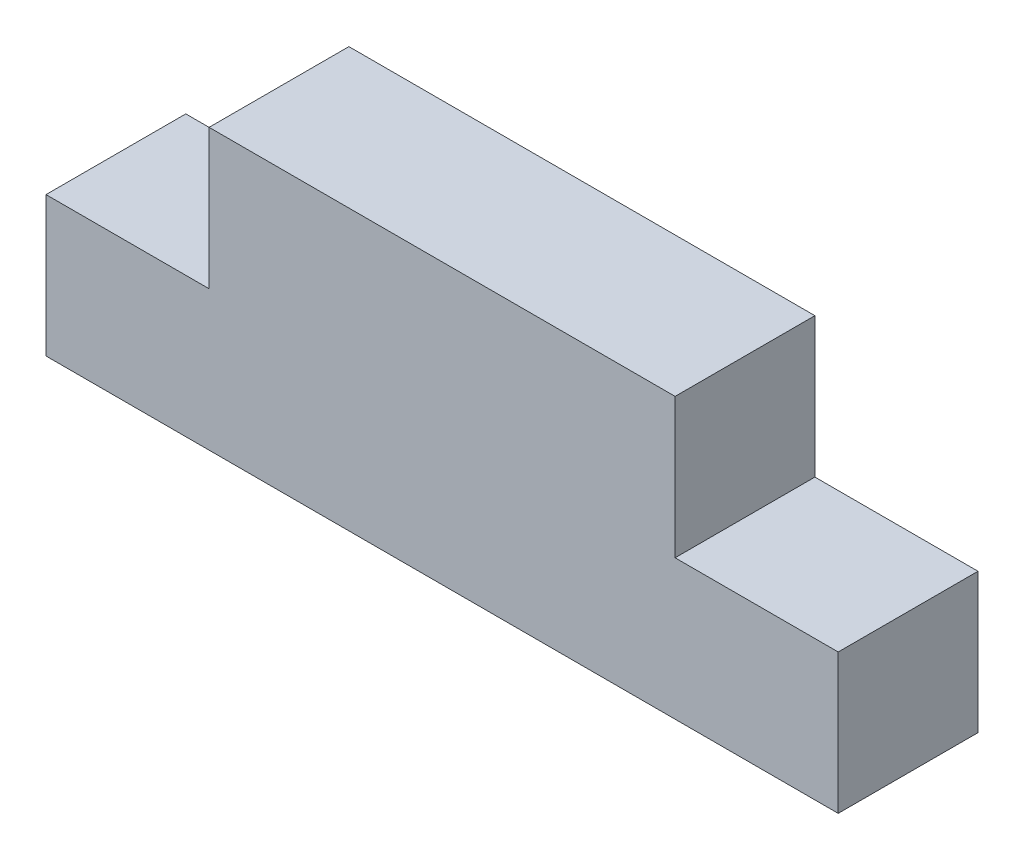
from build123d import *

# Parameters (mm, degrees)
RESSALTO_EXTRUS_O1_DEPTH = 6


with BuildPart() as part:
    # Esboço1 → Ressalto-extrusão1 (new body)
    with BuildSketch(Plane.XY):
        Polygon((7, 12), (7, 6), (0, 6), (0, 0), (34, 0), (34, 6), (27, 6), (27, 12), align=None)
    extrude(amount=RESSALTO_EXTRUS_O1_DEPTH)


solid = part.part
